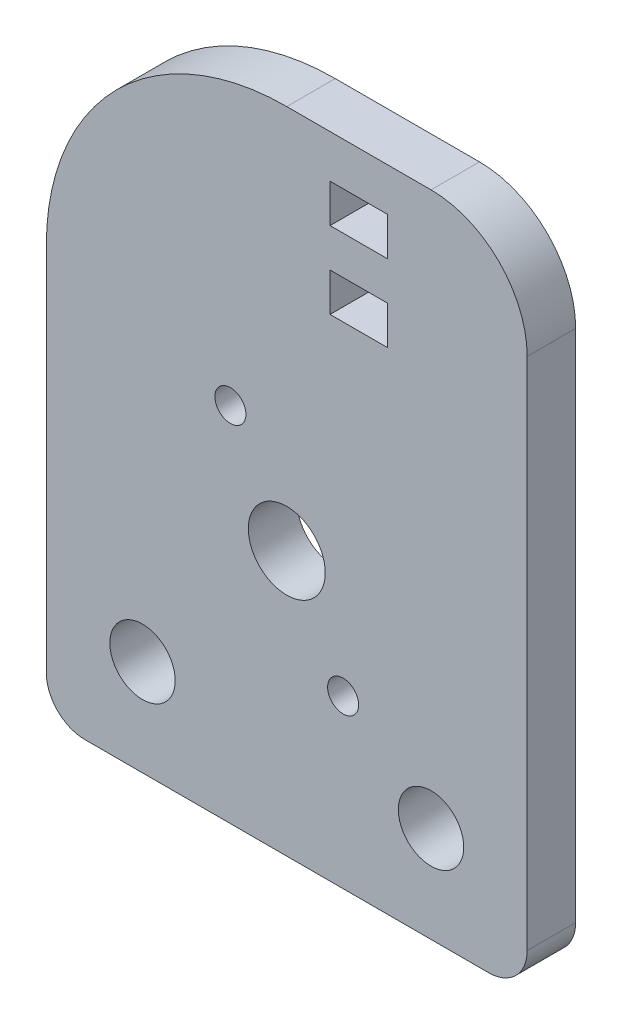
from build123d import *

# Parameters (mm, degrees)
SKETCH1_R           = 2.54
SKETCH1_R_2         = 2.159
BOSS_EXTRUDE1_DEPTH = 3.2004
FILLET1_R           = 6.35
FILLET2_R           = 2.54
SKETCH2_R           = 1.025
CUT_EXTRUDE1_DEPTH  = 3.2004
SKETCH3_W           = 3.81
SKETCH3_H           = 2.54
CUT_EXTRUDE2_DEPTH  = 3.2004


with BuildPart() as part:
    # Sketch1 → Boss-Extrude1 (new body)
    with BuildSketch(Plane.XY):
        with BuildLine():
            Line((15.875, 25.4), (15.875, 9.525))
            Line((15.875, 9.525), (15.875, -17.4625))
            Line((15.875, -17.4625), (-15.875, -17.4625))
            Line((-15.875, -17.4625), (-15.875, 9.525))
            ThreePointArc((-15.875, 9.525), (-11.225320151, 20.750320151), (0, 25.4))
            Line((0, 25.4), (15.875, 25.4))
        make_face()
        Circle(SKETCH1_R, mode=Mode.SUBTRACT)
        with Locations((-9.525, -11.1125)):
            Circle(SKETCH1_R_2, mode=Mode.SUBTRACT)
        with Locations((9.525, -11.1125)):
            Circle(SKETCH1_R_2, mode=Mode.SUBTRACT)
    extrude(amount=BOSS_EXTRUDE1_DEPTH)

    # Fillet1
    fillet1_edges = [part.edges().sort_by_distance(p)[0] for p in [
        (15.875, 25.4, 1.6002),
    ]]
    fillet(fillet1_edges, radius=FILLET1_R)

    # Fillet2
    fillet2_edges = [part.edges().sort_by_distance(p)[0] for p in [
        (15.875, -17.4625, 1.6002),
        (-15.875, -17.4625, 1.6002),
    ]]
    fillet(fillet2_edges, radius=FILLET2_R)

    # Sketch2 → Cut-Extrude1 (cut)
    with BuildSketch(Plane.XY.offset(3.2004)):
        with Locations((-3.7211, 6.44513426)):
            Circle(SKETCH2_R)
        with Locations((3.7211, -6.44513426)):
            Circle(SKETCH2_R)
    extrude(amount=-CUT_EXTRUDE1_DEPTH, mode=Mode.SUBTRACT)

    # Sketch3 → Cut-Extrude2 (cut)
    with BuildSketch(Plane.XY.offset(3.2004)):
        with Locations((4.7625, 21.292785454)):
            Rectangle(SKETCH3_W, SKETCH3_H)
        with Locations((4.7625, 16.212785454)):
            Rectangle(SKETCH3_W, SKETCH3_H)
    extrude(amount=-CUT_EXTRUDE2_DEPTH, mode=Mode.SUBTRACT)


solid = part.part
